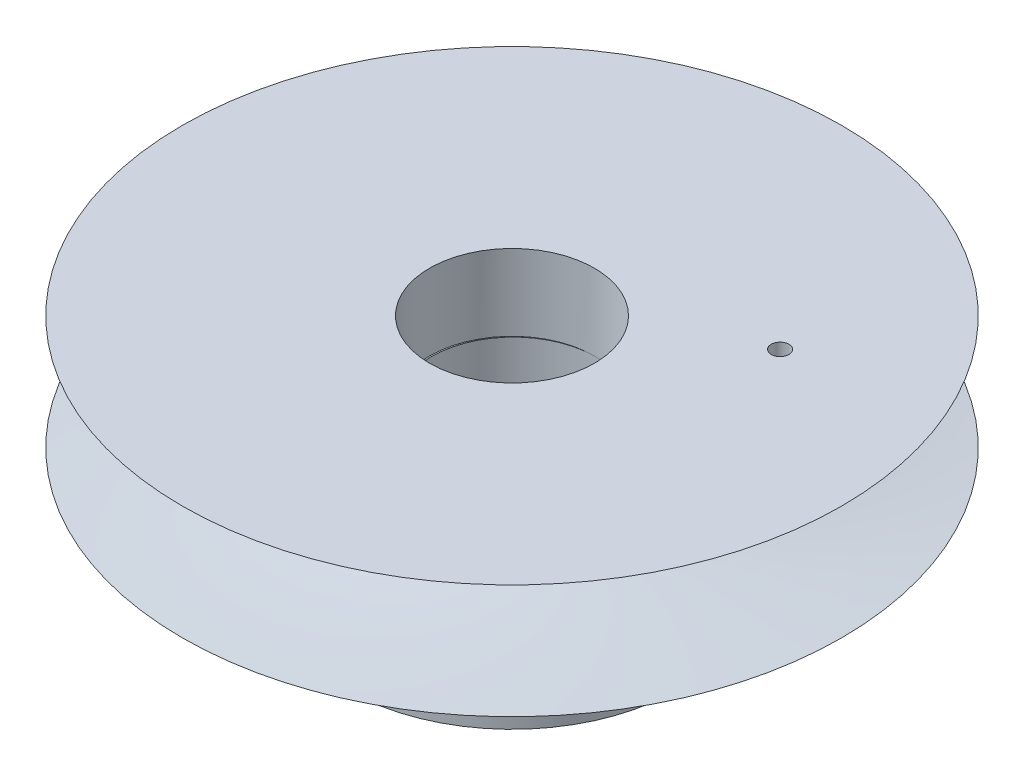
from build123d import *

# Parameters (mm, degrees)
SKETCH117_R           = 3.25
CUT_EXTRUDE4_DEPTH    = 3
SKETCH122_R           = 6.539767279
BOSS_EXTRUDE1_DEPTH   = 5
M2X0_4_TAPPED_HOLE1_D = 1.6
SKETCH125_R           = 3.25
CUT_EXTRUDE5_DEPTH    = 7
SKETCH126_R           = 0.35
CUT_EXTRUDE6_DEPTH    = 2


with BuildPart() as part:
    # Sketch9 → Revolve1 (revolve)
    with BuildSketch(Plane.XY):
        with BuildLine():
            Line((-4.703089141, -2.935363462), (8.296910859, -2.935363462))
            Line((8.296910859, -2.935363462), (8.296910859, 1.564636538))
            Line((8.296910859, 1.564636538), (-4.703089141, 1.564636538))
            add(Edge.make_bspline(
                [(-4.703089141, 1.564636538), (8.296910859, -1.435363462), (-4.703089141, -2.935363462)],
                knots=[0, 0, 0, 1, 1, 1], degree=2))
        make_face()
    revolve(axis=Axis((8.296910859, -2.935363462, 0), (0, 1, 0)))

    # Sketch117 → Cut-Extrude4 (cut)
    with BuildSketch(Plane(origin=(0, 1.564636538, 0), x_dir=(1, 0, 0), z_dir=(0, 1, 0))):
        with Locations((8.29691086, 0)):
            Circle(SKETCH117_R)
    extrude(amount=-CUT_EXTRUDE4_DEPTH, mode=Mode.SUBTRACT)

    # Sketch122 → Boss-Extrude1 (add)
    with BuildSketch(Plane(origin=(0, -2.935363462, 0), x_dir=(-1, 0, 0), z_dir=(0, -1, 0))):
        with Locations((-8.29691086, 0)):
            Circle(SKETCH122_R)
    extrude(amount=BOSS_EXTRUDE1_DEPTH)

    # M2x0.4 Tapped Hole1 (through all)
    with Locations(Plane(origin=(1.815385484, -5.431649491, -0.870852953), x_dir=(0.133162682, 0, -0.991094193), z_dir=(-0.991094193, 0, -0.133162682))):
        with Locations((0, 0)):
            Hole(M2X0_4_TAPPED_HOLE1_D / 2)

    # Sketch125 → Cut-Extrude5 (cut)
    with BuildSketch(Plane(origin=(0, -1.435363462, 0), x_dir=(1, 0, 0), z_dir=(0, 1, 0))):
        with Locations((8.350281981, 0)):
            Circle(SKETCH125_R)
    extrude(amount=-CUT_EXTRUDE5_DEPTH, mode=Mode.SUBTRACT)

    # Sketch126 → Cut-Extrude6 (cut)
    with BuildSketch(Plane(origin=(0, 1.564636538, 0), x_dir=(1, 0, 0), z_dir=(0, 1, 0))):
        with Locations((14.730684235, 4.136659271)):
            Circle(SKETCH126_R)
    extrude(amount=-CUT_EXTRUDE6_DEPTH, mode=Mode.SUBTRACT)


solid = part.part
